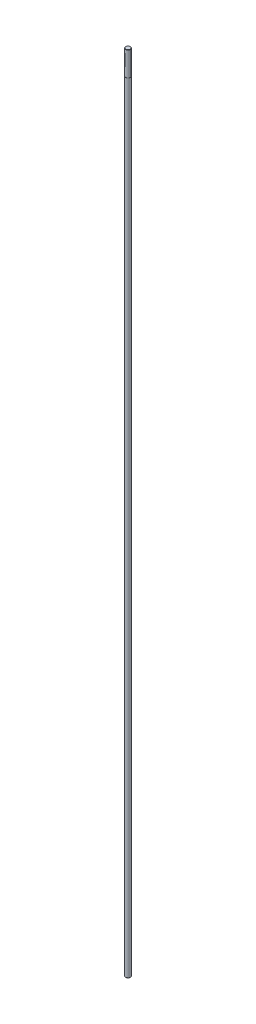
from build123d import *

# Parameters (mm, degrees)
SKETCH1_R           = 2.133333333
BOSS_EXTRUDE1_DEPTH = 640
SKETCH2_R           = 2
BOSS_EXTRUDE2_DEPTH = 20
CHAMFER1_SIZE       = 0.2
CHAMFER2_SIZE       = 0.5
SCALE1_SCALE        = 7.5


with BuildPart() as part:
    # Sketch1 → Boss-Extrude1 (new body)
    with BuildSketch(Plane(origin=(0, 0, 0), x_dir=(1, 0, 0), z_dir=(0, 1, 0))):
        Circle(SKETCH1_R)
    extrude(amount=BOSS_EXTRUDE1_DEPTH)

    # Sketch2 → Boss-Extrude2 (add)
    with BuildSketch(Plane(origin=(0, 640, 0), x_dir=(1, 0, 0), z_dir=(0, 1, 0))):
        Circle(SKETCH2_R)
    extrude(amount=BOSS_EXTRUDE2_DEPTH)

    # Chamfer1
    chamfer1_edges = [part.edges().sort_by_distance(p)[0] for p in [
        (-2, 660, 0),
    ]]
    chamfer(chamfer1_edges, length=CHAMFER1_SIZE)

    # Chamfer2
    chamfer2_edges = [part.edges().sort_by_distance(p)[0] for p in [
        (-2.133333333, 0, 0),
    ]]
    chamfer(chamfer2_edges, length=CHAMFER2_SIZE)


with BuildPart() as part_1:
    # Scale1: scaled about (0, 328.866878823, 0)
    add(part.part.scale(SCALE1_SCALE).moved(Location((0, -2137.634712349, 0))))


solid = part_1.part
